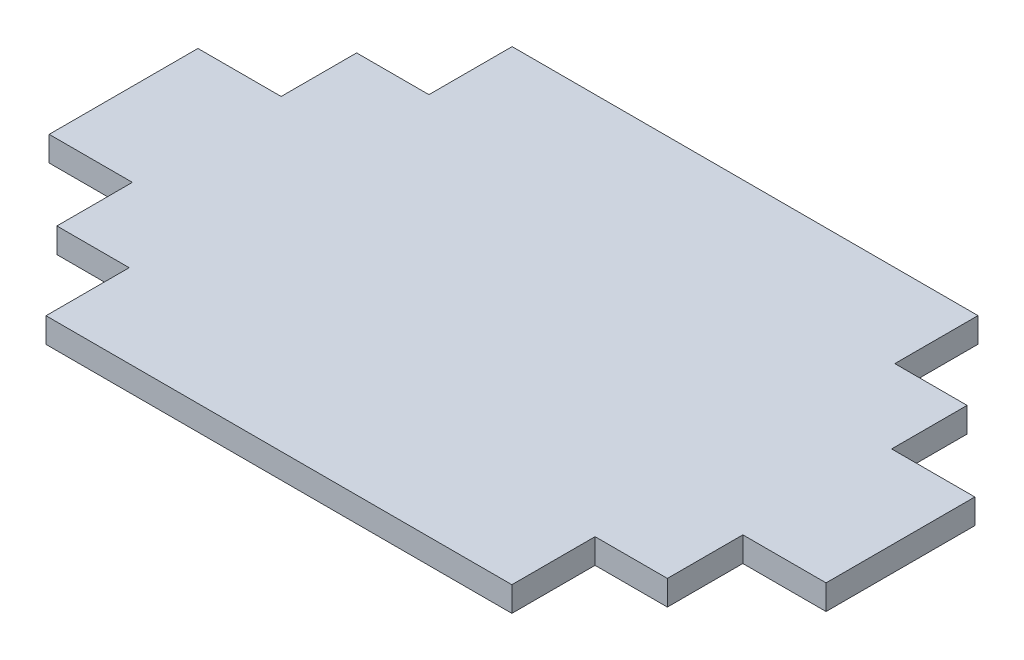
from build123d import *

# Parameters (mm, degrees)
SKETCH1_W           = 396.875
SKETCH1_H           = 238.125
BOSS_EXTRUDE1_DEPTH = 12.7
CUT_EXTRUDE1_DEPTH  = 13.7


with BuildPart() as part:
    # Sketch1 → Boss-Extrude1 (new body)
    with BuildSketch(Plane(origin=(0, 0, 0), x_dir=(1, 0, 0), z_dir=(0, 1, 0))):
        with Locations((198.4375, -119.0625)):
            Rectangle(SKETCH1_W, SKETCH1_H)
    extrude(amount=BOSS_EXTRUDE1_DEPTH)

    # Sketch2 → Cut-Extrude1 (cut, through all)
    with BuildSketch(Plane(origin=(0, 12.7, 0), x_dir=(1, 0, 0), z_dir=(0, 1, 0))):
        Polygon((79.4375, -238.125), (0, -238.125), (0, -195.625), (0, -157.0625), (42.5, -157.0625), (42.5, -195.625), (79.4375, -195.625), align=None)
        Polygon((79.4375, 0), (0, 0), (0, -42.5), (0, -81.0625), (42.5, -81.0625), (42.5, -42.5), (79.4375, -42.5), align=None)
        Polygon((317.4375, 0), (396.875, 0), (396.875, -42.5), (396.875, -81.0625), (354.375, -81.0625), (354.375, -42.5), (317.4375, -42.5), align=None)
        Polygon((317.4375, -238.125), (317.4375, -195.625), (354.375, -195.625), (354.375, -157.0625), (396.875, -157.0625), (396.875, -195.625), (396.875, -238.125), align=None)
    extrude(amount=-CUT_EXTRUDE1_DEPTH, mode=Mode.SUBTRACT)


solid = part.part
